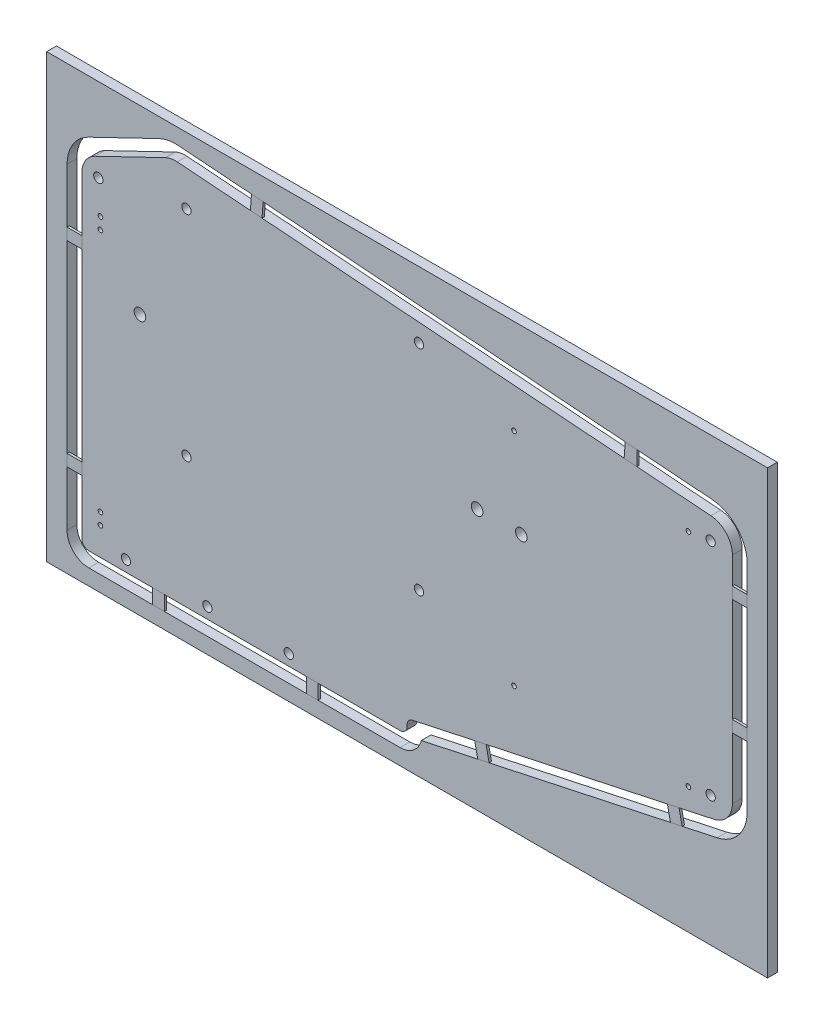
from build123d import *

# Parameters (mm, degrees)
SKETCH1_R              = 2
BOSS_EXTRUDE1_DEPTH    = 4.2
SKETCH3_R              = 2
SKETCH3_R_2            = 2.5
SKETCH3_R_3            = 1
CUT_EXTRUDE1_DEPTH     = 5.2
FILLET1_R              = 10
FILLET2_R              = 3
FILLET3_R              = 3
SKETCH5_W              = 310
SKETCH5_H              = 190
BOSS_EXTRUDE2_DEPTH    = 4.2
SKETCH6_W              = 6.35
SKETCH6_H              = 5
BOSS_EXTRUDE3_DEPTH    = 1
BOSS_EXTRUDE3_2_DEPTH  = 1
BOSS_EXTRUDE3_3_DEPTH  = 1
SKETCH6_W_2            = 5
SKETCH6_H_2            = 6.35
BOSS_EXTRUDE3_4_DEPTH  = 1
BOSS_EXTRUDE3_5_DEPTH  = 1
BOSS_EXTRUDE3_6_DEPTH  = 1
BOSS_EXTRUDE3_7_DEPTH  = 1
BOSS_EXTRUDE3_8_DEPTH  = 1
BOSS_EXTRUDE3_9_DEPTH  = 1
BOSS_EXTRUDE3_10_DEPTH = 1


with BuildPart() as part:
    # Sketch1 → Boss-Extrude1 (new body)
    with BuildSketch(Plane.XY):
        Polygon((0, 0), (0, 145.557213411), (38.329404323, 164.051877681), (279.774613656, 146.144103687), (279.774613656, 36.144103687), (139.774613656, 5.995765255), (140, 0), align=None)
        with Locations((45, 148.3671256)):
            Circle(SKETCH1_R, mode=Mode.SUBTRACT)
        with Locations((45, 56.3671256)):
            Circle(SKETCH1_R, mode=Mode.SUBTRACT)
        with Locations((145, 148.3671256)):
            Circle(SKETCH1_R, mode=Mode.SUBTRACT)
        with Locations((145, 56.3671256)):
            Circle(SKETCH1_R, mode=Mode.SUBTRACT)
    extrude(amount=BOSS_EXTRUDE1_DEPTH)

    # Sketch3 → Cut-Extrude1 (cut, through all)
    with BuildSketch(Plane.XY.offset(4.2)):
        with Locations((7.098408151, 141.006416768)):
            Circle(SKETCH3_R)
        with Locations((19, 4.76)):
            Circle(SKETCH3_R)
        with Locations((54, 4.76)):
            Circle(SKETCH3_R)
        with Locations((89, 4.76)):
            Circle(SKETCH3_R)
        with Locations((270.424613656, 137.461902613)):
            Circle(SKETCH3_R)
        with Locations((270.424613656, 42.672041086)):
            Circle(SKETCH3_R)
        with Locations((25, 99.051877681)):
            Circle(SKETCH3_R_2)
        with Locations((189, 99.051877681)):
            Circle(SKETCH3_R_2)
        with Locations((170, 99.051877681)):
            Circle(SKETCH3_R_2)
        with Locations((8, 12.025)):
            Circle(SKETCH3_R_3)
        with Locations((8, 17.025)):
            Circle(SKETCH3_R_3)
        with Locations((8, 127.025)):
            Circle(SKETCH3_R_3)
        with Locations((8, 122.025)):
            Circle(SKETCH3_R_3)
        with Locations((185.863031262, 136.144103687)):
            Circle(SKETCH3_R_3)
        with Locations((260.863031262, 136.144103687)):
            Circle(SKETCH3_R_3)
        with Locations((185.863031262, 41.144103687)):
            Circle(SKETCH3_R_3)
        with Locations((260.863031262, 41.144103687)):
            Circle(SKETCH3_R_3)
    extrude(amount=-CUT_EXTRUDE1_DEPTH, mode=Mode.SUBTRACT)

    # Fillet1
    fillet1_edges = [part.edges().sort_by_distance(p)[0] for p in [
        (0, 145.557213411, 2.1),
        (38.329404323, 164.051877681, 2.1),
        (279.774613656, 146.144103687, 2.1),
        (279.774613656, 36.144103687, 2.1),
    ]]
    fillet(fillet1_edges, radius=FILLET1_R)

    # Fillet2
    fillet2_edges = [part.edges().sort_by_distance(p)[0] for p in [
        (139.774613656, 5.995765255, 2.1),
    ]]
    fillet(fillet2_edges, radius=FILLET2_R)

    # Fillet3
    fillet3_edges = [part.edges().sort_by_distance(p)[0] for p in [
        (0, 0, 2.1),
        (140, 0, 2.1),
    ]]
    fillet(fillet3_edges, radius=FILLET3_R)


with BuildPart() as body_2:
    # Sketch5 → Boss-Extrude2 (new body)
    with BuildSketch(Plane.XY.offset(4.2)):
        with Locations((139.887306828, 81.852658058)):
            Rectangle(SKETCH5_W, SKETCH5_H)
        with BuildLine():
            Line((-6.35, 139.279139761), (-6.35, 3))
            ThreePointArc((-6.35, 3), (-3.611448404, -3.611448404), (3, -6.35))
            Line((3, -6.35), (136.885108366, -6.35))
            ThreePointArc((136.885108366, -6.35), (142.681514182, -4.336496413), (145.981431463, 0.836806499))
            Line((145.981431463, 0.836806499), (273.216604564, 28.236299778))
            ThreePointArc((273.216604564, 28.236299778), (282.494657904, 33.947453717), (286.124613656, 44.21989132))
            Line((286.124613656, 44.21989132), (286.124613656, 136.858327138))
            ThreePointArc((286.124613656, 136.858327138), (281.755750047, 147.983742671), (270.983956679, 153.163540704))
            Line((270.983956679, 153.163540704), (41.471240181, 170.186292438))
            ThreePointArc((41.471240181, 170.186292438), (37.209933012, 169.943706766), (33.156612155, 168.606479546))
            Line((33.156612155, 168.606479546), (2.894714997, 154.004540435))
            ThreePointArc((2.894714997, 154.004540435), (-3.847272471, 147.972559404), (-6.35, 139.279139761))
        make_face(mode=Mode.SUBTRACT)
    extrude(amount=-BOSS_EXTRUDE2_DEPTH)


with BuildPart() as body_3:
    # Sketch6 → Boss-Extrude3 (new body)
    with BuildSketch(Plane.XY.offset(4.2)):
        with Locations((-3.175, 113.371772914)):
            Rectangle(SKETCH6_W, SKETCH6_H)
    extrude(amount=-BOSS_EXTRUDE3_DEPTH)


with BuildPart() as body_4:
    # Sketch6 → Boss-Extrude3 2 (new body)
    with BuildSketch(Plane.XY.offset(4.2)):
        Polygon((72.963338707, 167.850551818), (72.493655025, 161.517945938), (77.493655025, 161.147100435), (77.963338707, 167.479706316), align=None)
    extrude(amount=-BOSS_EXTRUDE3_2_DEPTH)


with BuildPart() as body_5:
    # Sketch6 → Boss-Extrude3 3 (new body)
    with BuildSketch(Plane.XY.offset(4.2)):
        with Locations((-3.175, 29.112391133)):
            Rectangle(SKETCH6_W, SKETCH6_H)
    extrude(amount=-BOSS_EXTRUDE3_3_DEPTH)


with BuildPart() as body_6:
    # Sketch6 → Boss-Extrude3 4 (new body)
    with BuildSketch(Plane.XY.offset(4.2)):
        with Locations((32.965553525, -3.175)):
            Rectangle(SKETCH6_W_2, SKETCH6_H_2)
    extrude(amount=-BOSS_EXTRUDE3_4_DEPTH)


with BuildPart() as body_7:
    # Sketch6 → Boss-Extrude3 5 (new body)
    with BuildSketch(Plane.XY.offset(4.2)):
        with Locations((99.048318073, -3.175)):
            Rectangle(SKETCH6_W_2, SKETCH6_H_2)
    extrude(amount=-BOSS_EXTRUDE3_5_DEPTH)


with BuildPart() as body_8:
    # Sketch6 → Boss-Extrude3 6 (new body)
    with BuildSketch(Plane.XY.offset(4.2)):
        Polygon((168.953275808, 12.279252266), (170.2900735, 6.071557692), (175.178021984, 7.1241543), (173.841224292, 13.331848874), align=None)
    extrude(amount=-BOSS_EXTRUDE3_6_DEPTH)


with BuildPart() as body_9:
    # Sketch6 → Boss-Extrude3 7 (new body)
    with BuildSketch(Plane.XY.offset(4.2)):
        Polygon((251.831978077, 30.126789157), (253.168775769, 23.919094583), (258.168775769, 24.995820956), (256.831978077, 31.20351553), align=None)
    extrude(amount=-BOSS_EXTRUDE3_7_DEPTH)


with BuildPart() as body_10:
    # Sketch6 → Boss-Extrude3 8 (new body)
    with BuildSketch(Plane.XY.offset(4.2)):
        with Locations((282.949613656, 122.778121561)):
            Rectangle(SKETCH6_W, SKETCH6_H)
    extrude(amount=-BOSS_EXTRUDE3_8_DEPTH)


with BuildPart() as body_11:
    # Sketch6 → Boss-Extrude3 9 (new body)
    with BuildSketch(Plane.XY.offset(4.2)):
        with Locations((282.949613656, 73.068168903)):
            Rectangle(SKETCH6_W, SKETCH6_H)
    extrude(amount=-BOSS_EXTRUDE3_9_DEPTH)


with BuildPart() as body_12:
    # Sketch6 → Boss-Extrude3 10 (new body)
    with BuildSketch(Plane.XY.offset(4.2)):
        Polygon((233.679099892, 155.930408376), (233.20941621, 149.597802496), (238.679099892, 149.192120977), (238.679099892, 155.559562874), align=None)
    extrude(amount=-BOSS_EXTRUDE3_10_DEPTH)


solid = Compound([part.part, body_2.part, body_3.part, body_4.part, body_5.part, body_6.part, body_7.part, body_8.part, body_9.part, body_10.part, body_11.part, body_12.part])
